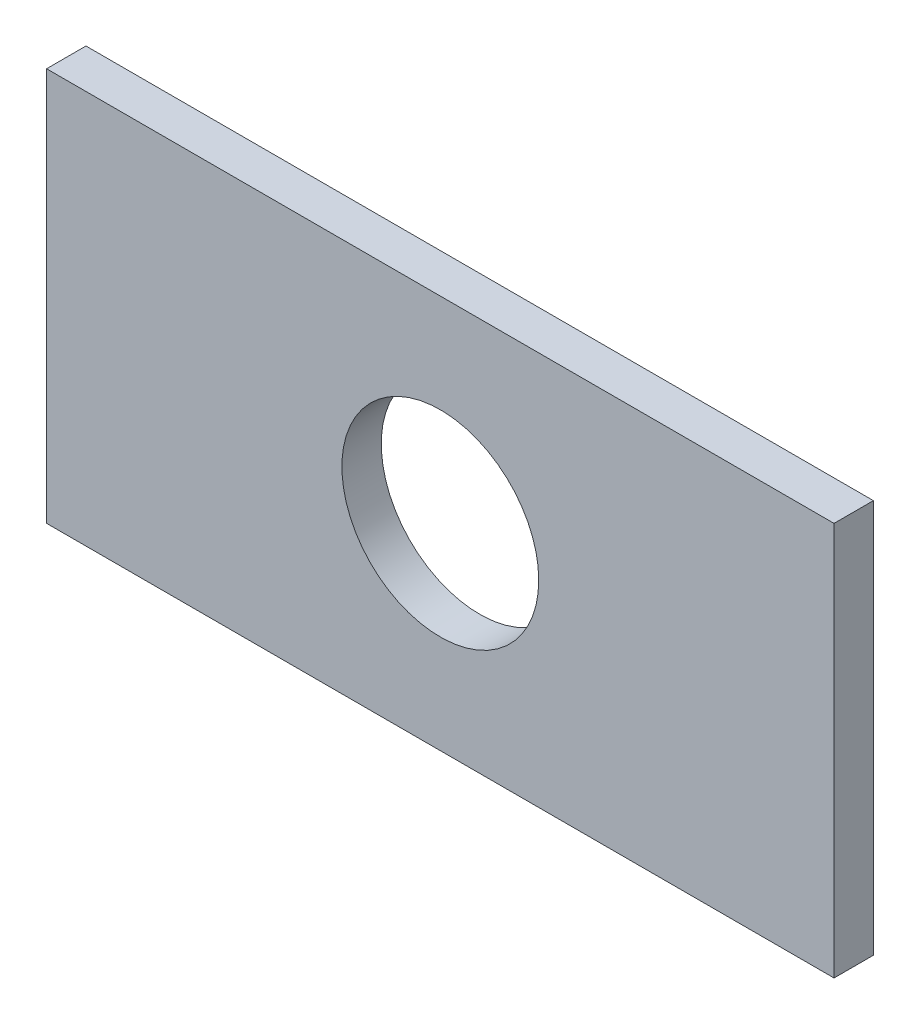
from build123d import *

# Parameters (mm, degrees)
SKETCH1_W           = 5080
SKETCH1_H           = 2540
SKETCH1_R           = 635
BOSS_EXTRUDE1_DEPTH = 127


with BuildPart() as part:
    # Sketch1 → Boss-Extrude1 (new body, symmetric)
    with BuildSketch(Plane.XY):
        Rectangle(SKETCH1_W, SKETCH1_H)
        Circle(SKETCH1_R, mode=Mode.SUBTRACT)
    extrude(amount=BOSS_EXTRUDE1_DEPTH, both=True)


solid = part.part
